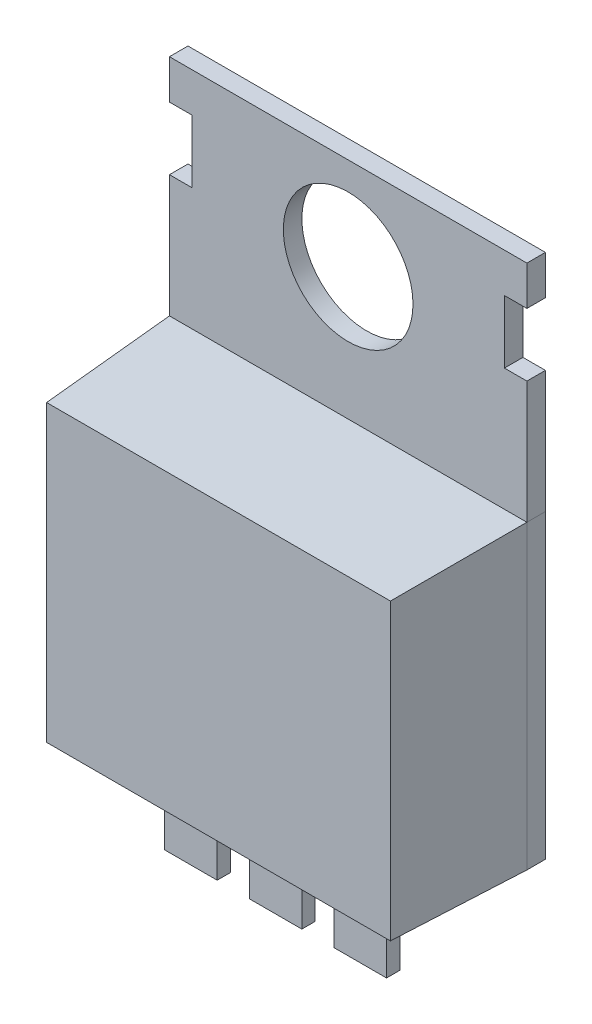
from build123d import *

# Parameters (mm, degrees)
SKETCH1_W             = 9.65
SKETCH1_H             = 4
BOSS_EXTRUDE1_DEPTH   = 8.13
CHAMFER2_SIZE         = 3.5
CHAMFER2_SIZE2        = 0.183427227
SKETCH4_W             = 9.65
SKETCH4_H             = 0.5
BOSS_EXTRUDE2_DEPTH   = 6.06
CHAMFER3_SIZE         = 3.5
CHAMFER3_SIZE2        = 0.183427227
CHAMFER4_SIZE         = 3.5
CHAMFER4_SIZE2        = 0.183427227
SKETCH5_W             = 7.59
SKETCH5_H             = 5.44
CUT_EXTRUDE1_DEPTH    = 0.5
SKETCH7_W             = 7.59
SKETCH7_H             = 5.44
BOSS_EXTRUDE3_DEPTH   = 0.5
SKETCH8_W             = 1.42
SKETCH8_H             = 0.36
BOSS_EXTRUDE4_DEPTH   = 2.46
BOSS_EXTRUDE4_2_DEPTH = 2.46
BOSS_EXTRUDE4_3_DEPTH = 2.46
SKETCH9_R             = 1.75
CUT_EXTRUDE2_DEPTH    = 2.46
SKETCH10_W            = 0.606244437
SKETCH10_H            = 1.697116576
CUT_EXTRUDE3_DEPTH    = 2.46


with BuildPart() as part:
    # Sketch1 → Boss-Extrude1 (new body)
    with BuildSketch(Plane(origin=(0, 0, 0), x_dir=(1, 0, 0), z_dir=(0, 1, 0))):
        Rectangle(SKETCH1_W, SKETCH1_H)
    extrude(amount=BOSS_EXTRUDE1_DEPTH)

    # Chamfer2
    chamfer2_edges = [part.edges().sort_by_distance(p)[0] for p in [
        (0, 8.13, 2),
    ]]
    chamfer2_side = [part.faces().sort_by_distance(p)[0] for p in [
        (0, 8.13, 0),
    ]]
    chamfer(chamfer2_edges, length=CHAMFER2_SIZE, length2=CHAMFER2_SIZE2, reference=chamfer2_side[0])

    # Chamfer3
    chamfer3_edges = [part.edges().sort_by_distance(p)[0] for p in [
        (4.825, 3.973286386, 2),
    ]]
    chamfer3_side = [part.faces().sort_by_distance(p)[0] for p in [
        (4.825, 4.025084823, -0.00830765),
    ]]
    chamfer(chamfer3_edges, length=CHAMFER3_SIZE, length2=CHAMFER3_SIZE2, reference=chamfer3_side[0])

    # Chamfer4
    chamfer4_edges = [part.edges().sort_by_distance(p)[0] for p in [
        (-4.825, 3.973286386, 2),
    ]]
    chamfer4_side = [part.faces().sort_by_distance(p)[0] for p in [
        (-4.825, 4.025084823, -0.00830765),
    ]]
    chamfer(chamfer4_edges, length=CHAMFER4_SIZE, length2=CHAMFER4_SIZE2, reference=chamfer4_side[0])

    # Sketch5 → Cut-Extrude1 (cut)
    with BuildSketch(Plane(origin=(0, 0, -2), x_dir=(-1, 0, 0), z_dir=(0, 0, -1))):
        with Locations((0, 5.41)):
            Rectangle(SKETCH5_W, SKETCH5_H)
    extrude(amount=-CUT_EXTRUDE1_DEPTH, mode=Mode.SUBTRACT)


with BuildPart() as body_2:
    # Sketch4 → Boss-Extrude2 (new body)
    with BuildSketch(Plane(origin=(0, 8.13, 0), x_dir=(1, 0, 0), z_dir=(0, 1, 0))):
        with Locations((0, 1.75)):
            Rectangle(SKETCH4_W, SKETCH4_H)
    extrude(amount=BOSS_EXTRUDE2_DEPTH)

    # Sketch9 → Cut-Extrude2 (cut)
    with BuildSketch(Plane.XY.offset(-1.5)):
        with Locations((0, 11.69)):
            Circle(SKETCH9_R)
    extrude(amount=-CUT_EXTRUDE2_DEPTH, mode=Mode.SUBTRACT)

    # Sketch10 → Cut-Extrude3 (cut)
    with BuildSketch(Plane.XY.offset(-1.5)):
        with Locations((-4.521877782, 12.279991165)):
            Rectangle(SKETCH10_W, SKETCH10_H)
        with Locations((4.521877782, 12.279991165)):
            Rectangle(SKETCH10_W, SKETCH10_H)
    extrude(amount=-CUT_EXTRUDE3_DEPTH, mode=Mode.SUBTRACT)


with BuildPart() as body_3:
    # Sketch7 → Boss-Extrude3 (new body)
    with BuildSketch(Plane(origin=(0, 0, -1.5), x_dir=(-1, 0, 0), z_dir=(0, 0, -1))):
        with Locations((0, 5.41)):
            Rectangle(SKETCH7_W, SKETCH7_H)
    extrude(amount=BOSS_EXTRUDE3_DEPTH)


with BuildPart() as body_4:
    # Sketch8 → Boss-Extrude4 (new body)
    with BuildSketch(Plane.XZ):
        with Locations((0, 0.28)):
            Rectangle(SKETCH8_W, SKETCH8_H)
    extrude(amount=BOSS_EXTRUDE4_DEPTH)


with BuildPart() as body_5:
    # Sketch8 → Boss-Extrude4 2 (new body)
    with BuildSketch(Plane.XZ):
        with Locations((2.286, 0.28)):
            Rectangle(SKETCH8_W, SKETCH8_H)
    extrude(amount=BOSS_EXTRUDE4_2_DEPTH)


with BuildPart() as body_6:
    # Sketch8 → Boss-Extrude4 3 (new body)
    with BuildSketch(Plane.XZ):
        with Locations((-2.286, 0.28)):
            Rectangle(SKETCH8_W, SKETCH8_H)
    extrude(amount=BOSS_EXTRUDE4_3_DEPTH)


solid = Compound([part.part, body_2.part, body_3.part, body_4.part, body_5.part, body_6.part])
